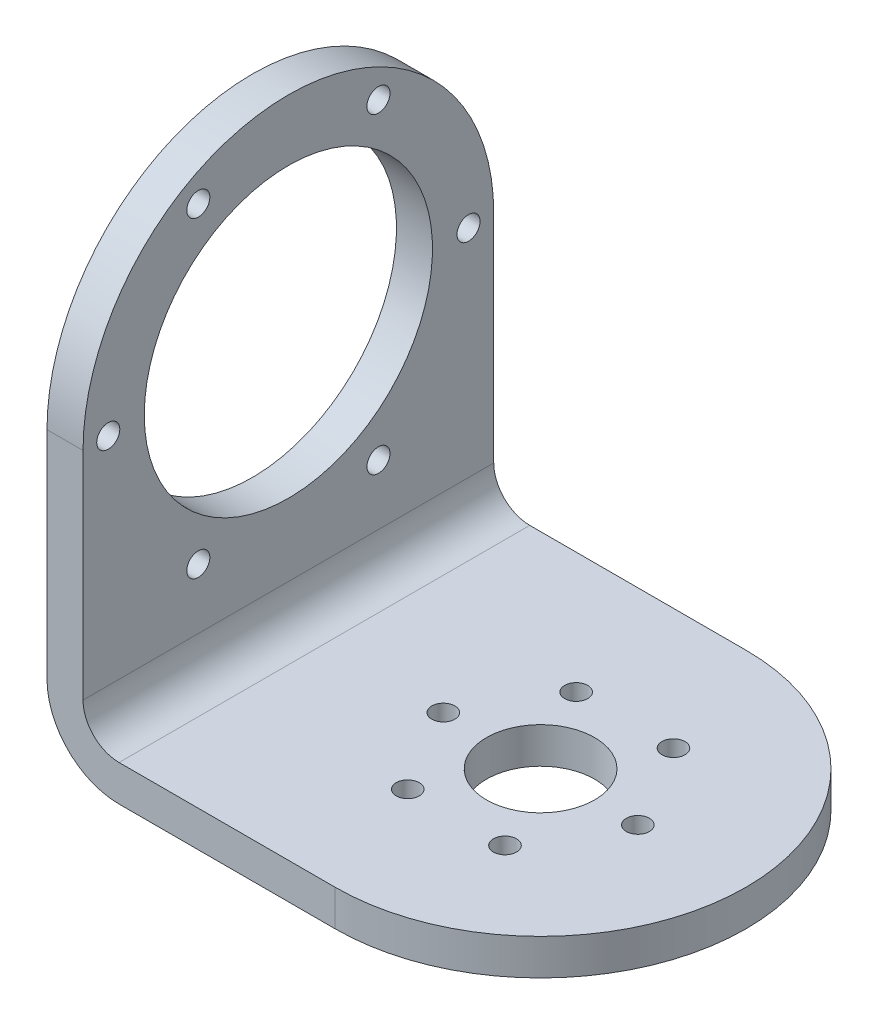
from build123d import *

# Parameters (mm, degrees)
SKETCH_1_R          = 28.5
SKETCH_1_W          = 5
SKETCH_1_H          = 57
EXTRUDE_1_DEPTH     = 5
SKETCH_2_R          = 1.6
SKETCH_2_R_2        = 20
EXTRUDE_2_DEPTH     = 5
FILLET_1_R          = 10
FILLET_2_R          = 5
SKETCH_3_R          = 1.6
SKETCH_3_R_2        = 7.5
CUT_EXTRUDE_1_DEPTH = 5


with BuildPart() as part:
    # 草图1 → 凸台-拉伸1 (new body)
    with BuildSketch(Plane(origin=(0, 0, 0), x_dir=(1, 0, 0), z_dir=(0, 1, 0))):
        with BuildLine():
            ThreePointArc((0, -28.5), (-28.5, 0), (0, 28.5))
            Line((0, 28.5), (-35, 28.5))
            Line((-35, 28.5), (-35, -28.5))
            Line((-35, -28.5), (0, -28.5))
        make_face()
        Circle(SKETCH_1_R)
        with Locations((-37.5, 0)):
            Rectangle(SKETCH_1_W, SKETCH_1_H)
    extrude(amount=EXTRUDE_1_DEPTH)

    # 草图2 → 凸台-拉伸2 (add)
    with BuildSketch(Plane.ZY.offset(40)):
        with BuildLine():
            Line((28.5, 0), (28.5, 40))
            ThreePointArc((28.5, 40), (0, 68.5), (-28.5, 40))
            Line((-28.5, 40), (-28.5, 0))
            Line((-28.5, 0), (28.5, 0))
        make_face()
        with Locations((12.5, 61.650635095)):
            Circle(SKETCH_2_R, mode=Mode.SUBTRACT)
        with Locations((-12.5, 18.349364905)):
            Circle(SKETCH_2_R, mode=Mode.SUBTRACT)
        with Locations((12.5, 18.349364905)):
            Circle(SKETCH_2_R, mode=Mode.SUBTRACT)
        with Locations((-25, 40)):
            Circle(SKETCH_2_R, mode=Mode.SUBTRACT)
        with Locations((-12.5, 61.650635095)):
            Circle(SKETCH_2_R, mode=Mode.SUBTRACT)
        with Locations((0, 40)):
            Circle(SKETCH_2_R_2, mode=Mode.SUBTRACT)
        with Locations((25, 40)):
            Circle(SKETCH_2_R, mode=Mode.SUBTRACT)
    extrude(amount=-EXTRUDE_2_DEPTH)

    # 圆角1
    fillet_1_edges = [part.edges().sort_by_distance(p)[0] for p in [
        (-40, 0, 0),
    ]]
    fillet(fillet_1_edges, radius=FILLET_1_R)

    # 圆角2
    fillet_2_edges = [part.edges().sort_by_distance(p)[0] for p in [
        (-35, 5, 0),
    ]]
    fillet(fillet_2_edges, radius=FILLET_2_R)

    # 草图3 → 切除-拉伸1 (cut)
    with BuildSketch(Plane(origin=(0, 5, 0), x_dir=(1, 0, 0), z_dir=(0, 1, 0))):
        with Locations((13.5, 0)):
            Circle(SKETCH_3_R)
        with Locations((6.75, -11.691342951)):
            Circle(SKETCH_3_R)
        with Locations((-6.75, -11.691342951)):
            Circle(SKETCH_3_R)
        with Locations((-13.5, 0)):
            Circle(SKETCH_3_R)
        with Locations((-6.75, 11.691342951)):
            Circle(SKETCH_3_R)
        with Locations((6.75, 11.691342951)):
            Circle(SKETCH_3_R)
        Circle(SKETCH_3_R_2)
    extrude(amount=-CUT_EXTRUDE_1_DEPTH, mode=Mode.SUBTRACT)


solid = part.part
